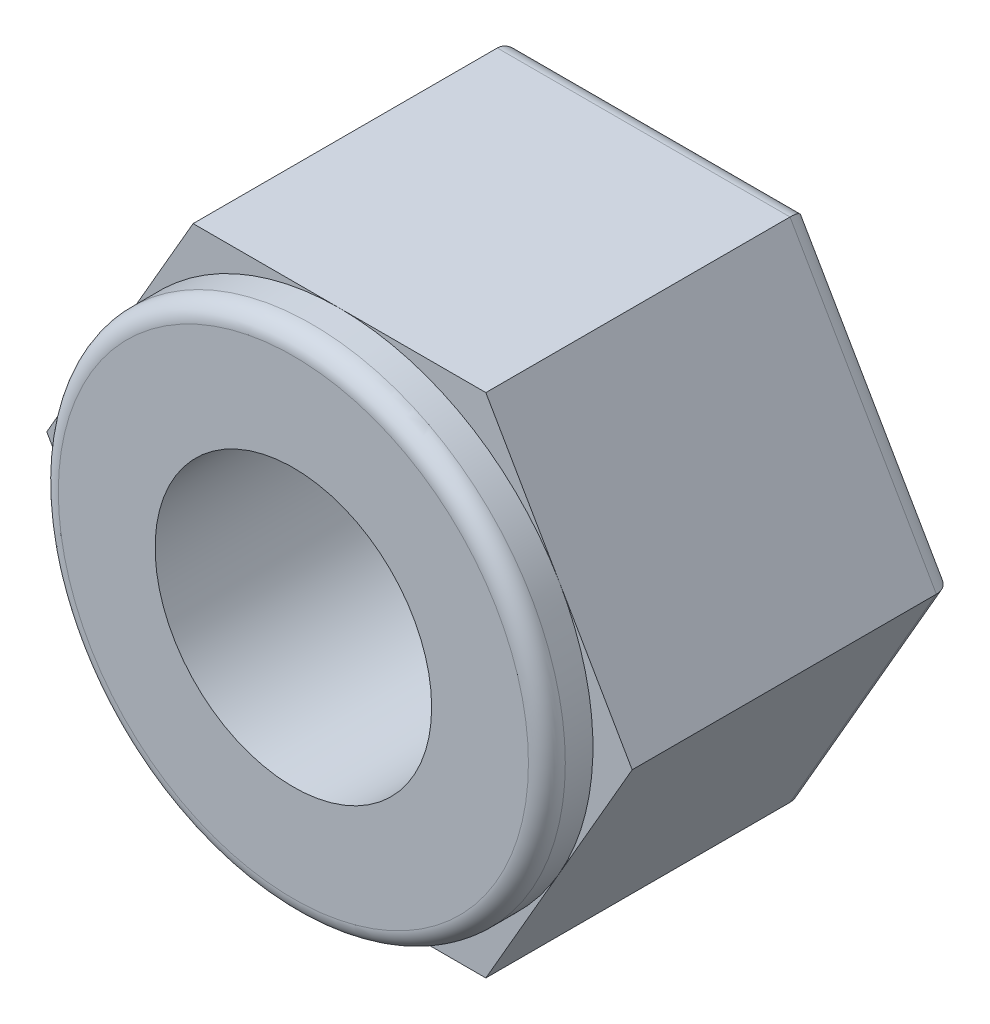
from build123d import *

# Parameters (mm, degrees)
SKETCH_1_R      = 1.5
EXTRUDE_1_DEPTH = 3.5
SKETCH_2_R      = 2.75
SKETCH_2_R_2    = 1.5
EXTRUDE_2_DEPTH = 0.5
FILLET_4_R      = 0.2
FILLET_5_R      = 0.2


with BuildPart() as part:
    # 草图1 → 凸台-拉伸1 (new body)
    with BuildSketch(Plane.XY):
        Polygon((3.175426481, 0), (1.58771324, 2.75), (-1.58771324, 2.75), (-3.175426481, 0), (-1.58771324, -2.75), (1.58771324, -2.75), align=None)
        Circle(SKETCH_1_R, mode=Mode.SUBTRACT)
    extrude(amount=EXTRUDE_1_DEPTH)

    # 草图2 → 凸台-拉伸2 (add)
    with BuildSketch(Plane.XY.offset(3.5)):
        Circle(SKETCH_2_R)
        Circle(SKETCH_2_R_2, mode=Mode.SUBTRACT)
    extrude(amount=EXTRUDE_2_DEPTH)

    # 圆角4
    fillet_4_edges = [part.edges().sort_by_distance(p)[0] for p in [
        (-2.75, 0, 4),
    ]]
    fillet(fillet_4_edges, radius=FILLET_4_R)

    # 圆角5
    fillet_5_edges = [part.edges().sort_by_distance(p)[0] for p in [
        (0, -2.75, 0),
        (-2.38156986, -1.375, 0),
        (-2.38156986, 1.375, 0),
        (0, 2.75, 0),
        (2.38156986, 1.375, 0),
        (2.38156986, -1.375, 0),
    ]]
    fillet(fillet_5_edges, radius=FILLET_5_R)


solid = part.part
